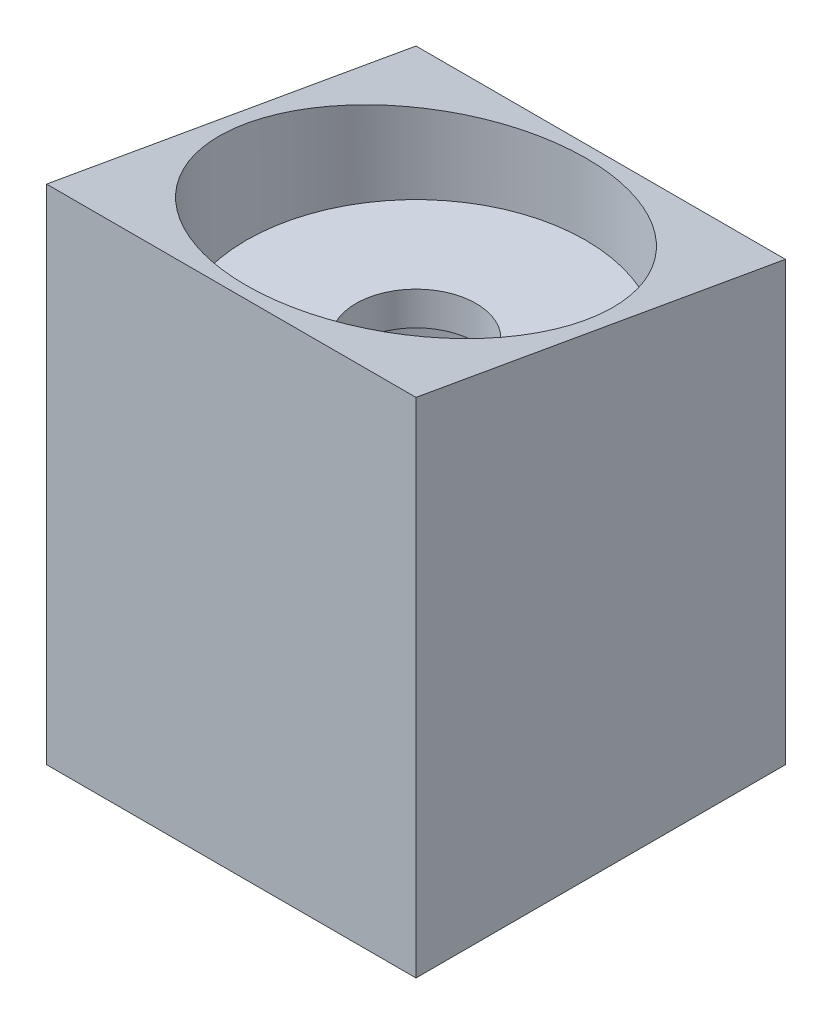
from build123d import *

# Parameters (mm, degrees)
SKETCH2_R                = 10.1
SKETCH2_R_2              = 3.575
BOSS_EXTRUDE1_DEPTH      = 2
SKETCH3_W                = 22
SKETCH3_H                = 22
SKETCH3_R                = 10.125
BOSS_EXTRUDE2_DEPTH      = 8
BOSS_EXTRUDE2_DEPTH_BACK = 22
SKETCH5_R                = 0.985
CUT_EXTRUDE2_DEPTH       = 6
CUT_EXTRUDE3_DEPTH       = 23


with BuildPart() as part:
    # Sketch2 → Boss-Extrude1 (new body)
    with BuildSketch(Plane(origin=(0, 0, 0), x_dir=(1, 0, 0), z_dir=(0, 1, 0))):
        Circle(SKETCH2_R)
        Circle(SKETCH2_R_2, mode=Mode.SUBTRACT)
    extrude(amount=BOSS_EXTRUDE1_DEPTH)


with BuildPart() as body_2:
    # Sketch3 → Boss-Extrude2 (new body, two sides)
    with BuildSketch(Plane(origin=(0, 2, 0), x_dir=(1, 0, 0), z_dir=(0, 1, 0))) as boss_extrude2_sk:
        Rectangle(SKETCH3_W, SKETCH3_H)
        Circle(SKETCH3_R, mode=Mode.SUBTRACT)
    extrude(amount=BOSS_EXTRUDE2_DEPTH)
    extrude(boss_extrude2_sk.sketch, amount=-BOSS_EXTRUDE2_DEPTH_BACK)

    # Sketch5 → Cut-Extrude2 (cut)
    with BuildSketch(Plane(origin=(0, -20, 0), x_dir=(-1, 0, 0), z_dir=(0, -1, 0))):
        with Locations((9.25, -9)):
            Circle(SKETCH5_R)
        with Locations((9.25, 9)):
            Circle(SKETCH5_R)
        with Locations((-9.25, 9)):
            Circle(SKETCH5_R)
        with Locations((-9.25, -9)):
            Circle(SKETCH5_R)
    extrude(amount=-CUT_EXTRUDE2_DEPTH, mode=Mode.SUBTRACT)

    # Sketch6 → Cut-Extrude3 (cut, through all)
    with BuildSketch(Plane(origin=(11, 0, 0), x_dir=(0, 0, -1), z_dir=(1, 0, 0))):
        Polygon((11, 6.06291723), (-11, 9.942110806), (-11, 10), (11, 10), align=None)
    extrude(amount=-CUT_EXTRUDE3_DEPTH, mode=Mode.SUBTRACT)


solid = Compound([part.part, body_2.part])
